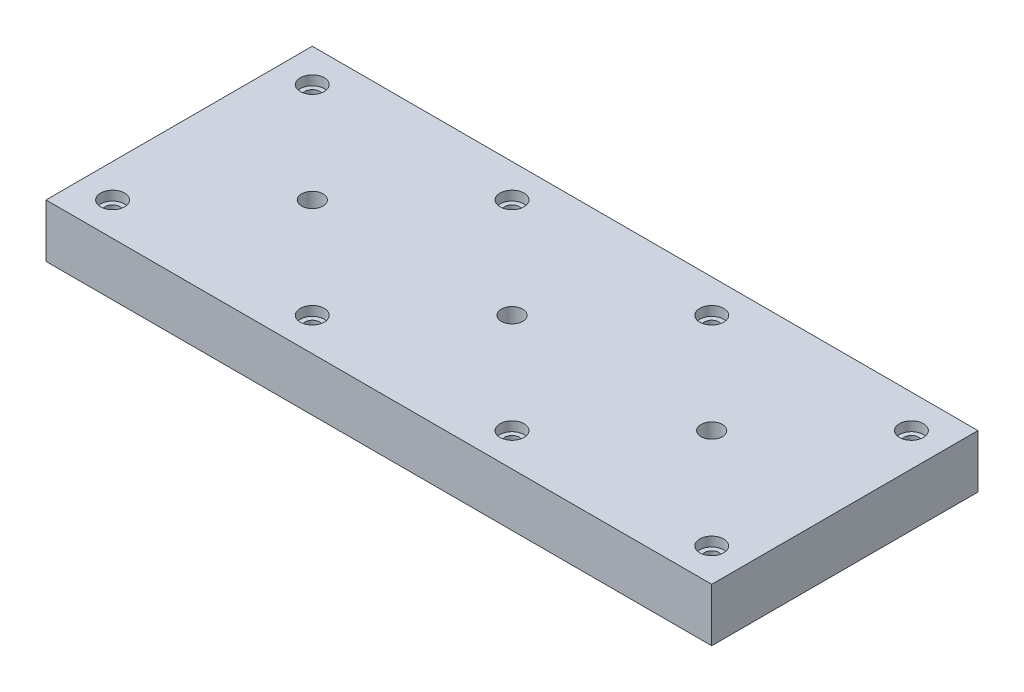
from build123d import *

# Parameters (mm, degrees)
ESBO_O1_W                                            = 500
ESBO_O1_H                                            = 200
RESSALTO_EXTRUS_O1_DEPTH                             = 40
REBAIXO_PARA_PARAFUSO_ALLEN_SEXTAVADO_DE_D           = 11
REBAIXO_PARA_PARAFUSO_ALLEN_SEXTAVADO_DE_DEPTH       = 40
REBAIXO_PARA_PARAFUSO_ALLEN_SEXTAVADO_DE_CBORE_D     = 18
REBAIXO_PARA_PARAFUSO_ALLEN_SEXTAVADO_DE_CBORE_DEPTH = 7.1
FURO_ROSCADO_DE_M18X2_0_D                            = 16
FURO_ROSCADO_DE_M18X2_0_DEPTH                        = 40


with BuildPart() as part:
    # Esboço1 → Ressalto-extrusão1 (new body)
    with BuildSketch(Plane(origin=(0, 0, 0), x_dir=(1, 0, 0), z_dir=(0, 1, 0))):
        Rectangle(ESBO_O1_W, ESBO_O1_H)
    extrude(amount=RESSALTO_EXTRUS_O1_DEPTH)

    # Rebaixo para parafuso Allen sextavado de M101
    with Locations(Plane(origin=(0, 40, 0), x_dir=(1, 0, 0), z_dir=(0, 1, 0))):
        with Locations((-225, 75), (-75, 75), (75, 75), (-75, -75), (75, -75), (-225, -75), (225, 75), (225, -75)):
            CounterBoreHole(REBAIXO_PARA_PARAFUSO_ALLEN_SEXTAVADO_DE_D / 2, REBAIXO_PARA_PARAFUSO_ALLEN_SEXTAVADO_DE_CBORE_D / 2, REBAIXO_PARA_PARAFUSO_ALLEN_SEXTAVADO_DE_CBORE_DEPTH, depth=REBAIXO_PARA_PARAFUSO_ALLEN_SEXTAVADO_DE_DEPTH)

    # Furo roscado de M18x2.0
    with Locations(Plane(origin=(0, 40, 0), x_dir=(1, 0, 0), z_dir=(0, 1, 0))):
        with Locations((-150, 0), (0, 0), (150, 0)):
            Hole(FURO_ROSCADO_DE_M18X2_0_D / 2, depth=FURO_ROSCADO_DE_M18X2_0_DEPTH)


solid = part.part
